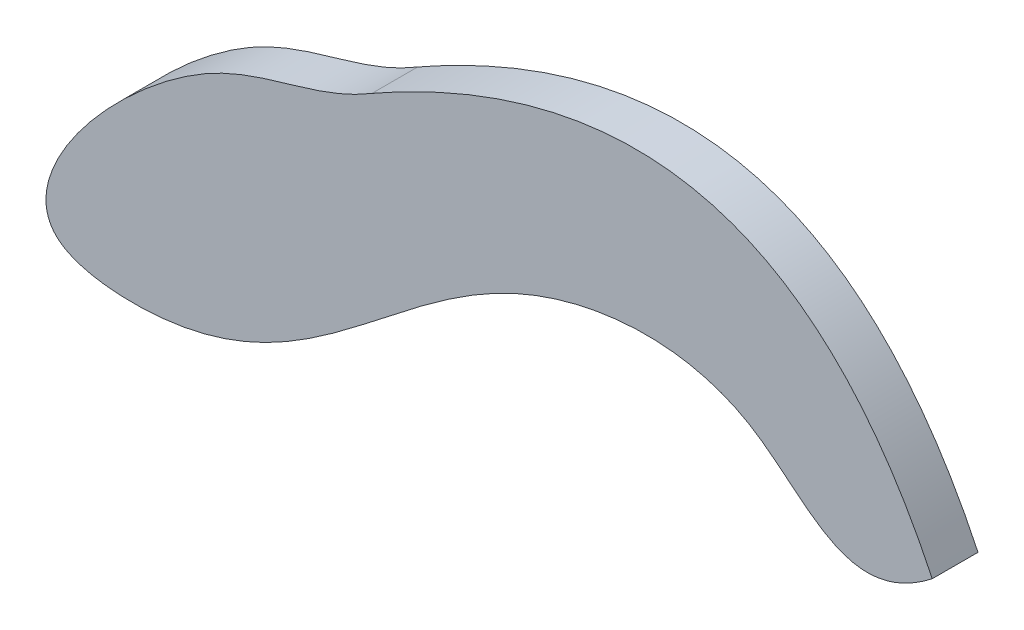
from build123d import *

# Parameters (mm, degrees)
BOSS_EXTRUDE1_DEPTH = 7


with BuildPart() as part:
    # Sketch1 → Boss-Extrude1 (new body)
    with BuildSketch(Plane.XY):
        with BuildLine():
            add(Edge.make_bspline(
                [(-73.851268358, 4.792172897), (-14.355344206, 38.573386239), (11.903404539, -16.646495327)],
                knots=[0, 0, 0, 1, 1, 1], degree=2))
            add(Edge.make_bspline(
                [(11.903404539, -16.646495327), (-1.143092735, -26.827377656), (-13.705810716, -3.204309558), (-64.701174526, -7.709760805), (-85.493119725, -44.014058563), (-135.9427577, -39.431649698), (-101.00884988, 0.41480069), (-82.528171317, -0.435012109), (-73.851268358, 4.792172897)],
                knots=[0, 0, 0, 0, 0.144374147, 0.307193404, 0.610894844, 0.682012232, 0.873530237, 1, 1, 1, 1], degree=3))
        make_face()
    extrude(amount=BOSS_EXTRUDE1_DEPTH)


solid = part.part
